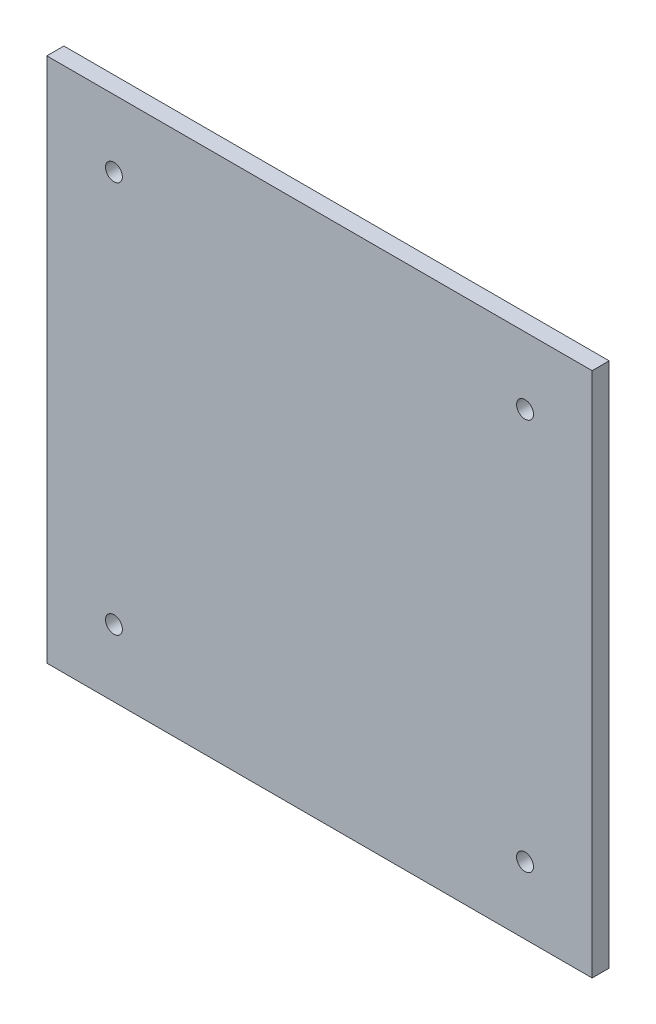
from build123d import *

# Parameters (mm, degrees)
PROFILE_SKETCH_W        = 101.599999844
PROFILE_SKETCH_H        = 97.999999956
PROFILE_EXTRUDE_DEPTH   = 3.175
MOUNTING_HOLE_SKETCH_R  = 1.575
MOUNTING_HOLE_CUT_DEPTH = 4.175


with BuildPart() as part:
    # Profile Sketch → Profile Extrude (new body)
    with BuildSketch(Plane.XY):
        Rectangle(PROFILE_SKETCH_W, PROFILE_SKETCH_H)
    extrude(amount=PROFILE_EXTRUDE_DEPTH)

    # Mounting Hole Sketch → Mounting Hole Cut (cut, through all)
    with BuildSketch(Plane.XY.offset(3.175)):
        with Locations((-38.299999922, 36.499999978)):
            Circle(MOUNTING_HOLE_SKETCH_R)
        with Locations((38.299999922, 36.499999978)):
            Circle(MOUNTING_HOLE_SKETCH_R)
        with Locations((38.299999922, -36.499999978)):
            Circle(MOUNTING_HOLE_SKETCH_R)
        with Locations((-38.299999922, -36.499999978)):
            Circle(MOUNTING_HOLE_SKETCH_R)
    extrude(amount=-MOUNTING_HOLE_CUT_DEPTH, mode=Mode.SUBTRACT)


solid = part.part
